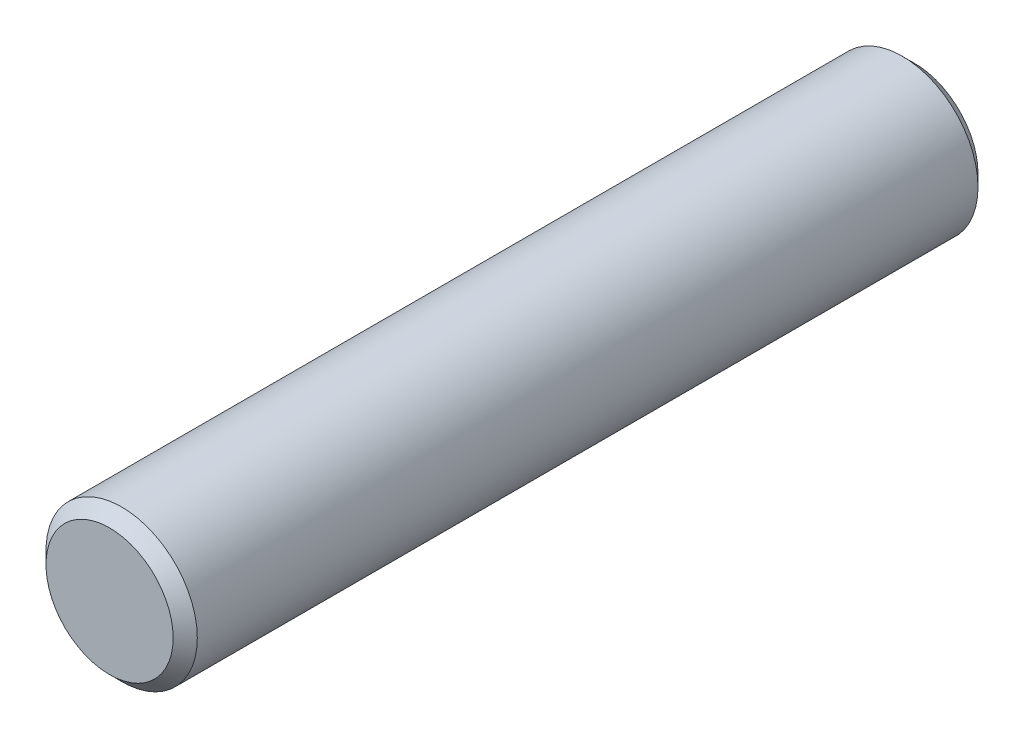
from build123d import *

# Parameters (mm, degrees)
SKETCH1_R      = 2.3876
EXTRUDE1_DEPTH = 12.7
CHAMFER1_SIZE  = 0.381


with BuildPart() as part:
    # Sketch1 → Extrude1 (new body, symmetric)
    with BuildSketch(Plane.XY):
        Circle(SKETCH1_R)
    extrude(amount=EXTRUDE1_DEPTH, both=True)

    # Chamfer1
    chamfer1_edges = [part.edges().sort_by_distance(p)[0] for p in [
        (-2.3876, 0, -12.7),
        (-2.3876, 0, 12.7),
    ]]
    chamfer(chamfer1_edges, length=CHAMFER1_SIZE)


solid = part.part
